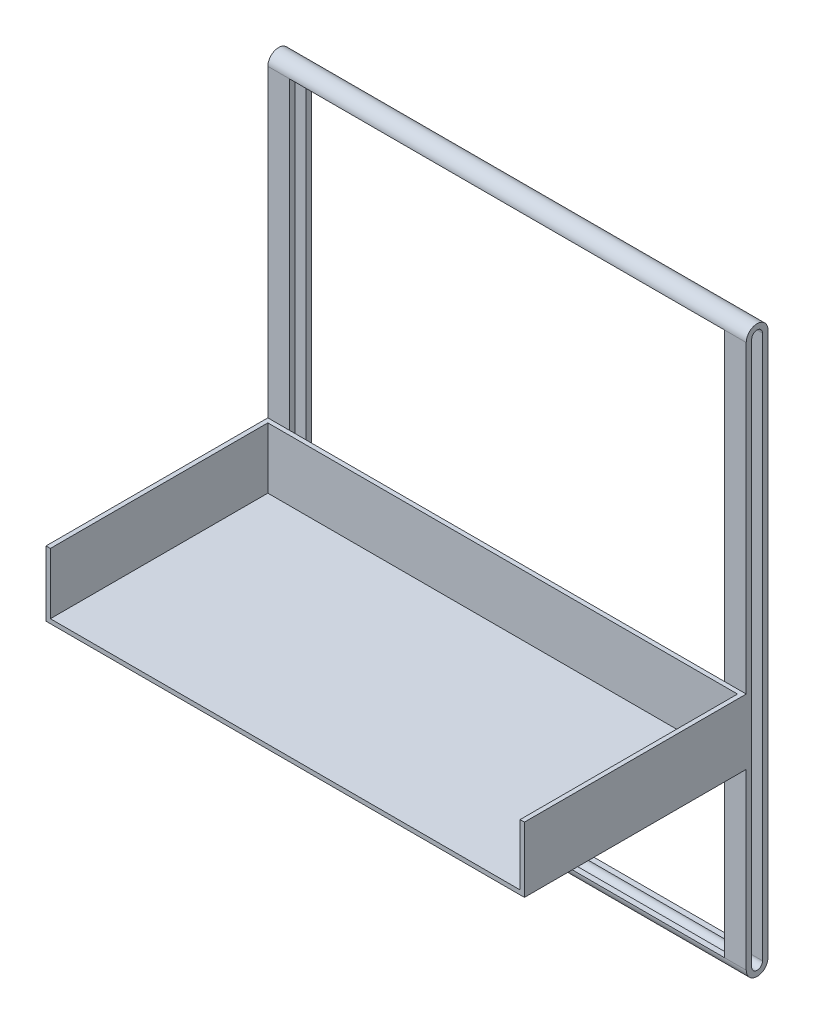
from build123d import *

# Parameters (mm, degrees)
BOSS_EXTRU_1_DEPTH      = 220
ENL_V_MAT_EXTRU_1_REACH = 222
ESQUISSE4_W             = 200
ESQUISSE4_H             = 250
ENL_V_MAT_EXTRU_2_DEPTH = 200
ESQUISSE5_W             = 220
ESQUISSE5_H             = 30
BOSS_EXTRU_2_DEPTH      = 2
ESQUISSE7_W             = 220
ESQUISSE7_H             = 2
BOSS_EXTRU_4_DEPTH      = 100
ESQUISSE8_W             = 2
ESQUISSE8_H             = 28
BOSS_EXTRU_5_DEPTH      = 100


with BuildPart() as part:
    # Esquisse1 → Boss.-Extru.1 (new body)
    with BuildSketch(Plane(origin=(0, 0, 0), x_dir=(0, 0, -1), z_dir=(1, 0, 0))):
        with BuildLine():
            Line((0, 0), (0, -250))
            ThreePointArc((0, -250), (5, -255), (10, -250))
            Line((10, -250), (10, 0))
            ThreePointArc((10, 0), (5, 5), (0, 0))
        make_face()
    extrude(amount=BOSS_EXTRU_1_DEPTH)

    # Esquisse2 → Enlèv. mat.-Extru.1 (cut, up to next)
    with BuildSketch(Plane.ZY, mode=Mode.PRIVATE) as enl_v_mat_extru_1_sk1:
        with BuildLine():
            Line((-7.5, 0), (-7.5, -250))
            ThreePointArc((-7.5, -250), (-5, -252.5), (-2.5, -250))
            Line((-2.5, -250), (-2.5, 0))
            ThreePointArc((-2.5, 0), (-5, 2.5), (-7.5, 0))
        make_face()
    enl_v_mat_extru_1_tool1 = extrude(enl_v_mat_extru_1_sk1.sketch, amount=-ENL_V_MAT_EXTRU_1_REACH, mode=Mode.PRIVATE) & part.part
    add(enl_v_mat_extru_1_tool1.solids().sort_by_distance((0, -125, -5))[0], mode=Mode.SUBTRACT)

    # Esquisse4 → Enlèv. mat.-Extru.2 (cut)
    with BuildSketch(Plane.XY):
        with Locations((110, -125)):
            Rectangle(ESQUISSE4_W, ESQUISSE4_H)
    extrude(amount=-ENL_V_MAT_EXTRU_2_DEPTH, mode=Mode.SUBTRACT)

    # Esquisse5 → Boss.-Extru.2 (add)
    with BuildSketch(Plane.XY):
        with Locations((110, -155)):
            Rectangle(ESQUISSE5_W, ESQUISSE5_H)
    extrude(amount=BOSS_EXTRU_2_DEPTH)

    # Esquisse7 → Boss.-Extru.4 (add)
    with BuildSketch(Plane.XY.offset(2)):
        with Locations((110, -169)):
            Rectangle(ESQUISSE7_W, ESQUISSE7_H)
    extrude(amount=BOSS_EXTRU_4_DEPTH)

    # Esquisse8 → Boss.-Extru.5 (add)
    with BuildSketch(Plane.XY.offset(2)):
        with Locations((1, -154)):
            Rectangle(ESQUISSE8_W, ESQUISSE8_H)
        with Locations((219, -154)):
            Rectangle(ESQUISSE8_W, ESQUISSE8_H)
    extrude(amount=BOSS_EXTRU_5_DEPTH)


solid = part.part
